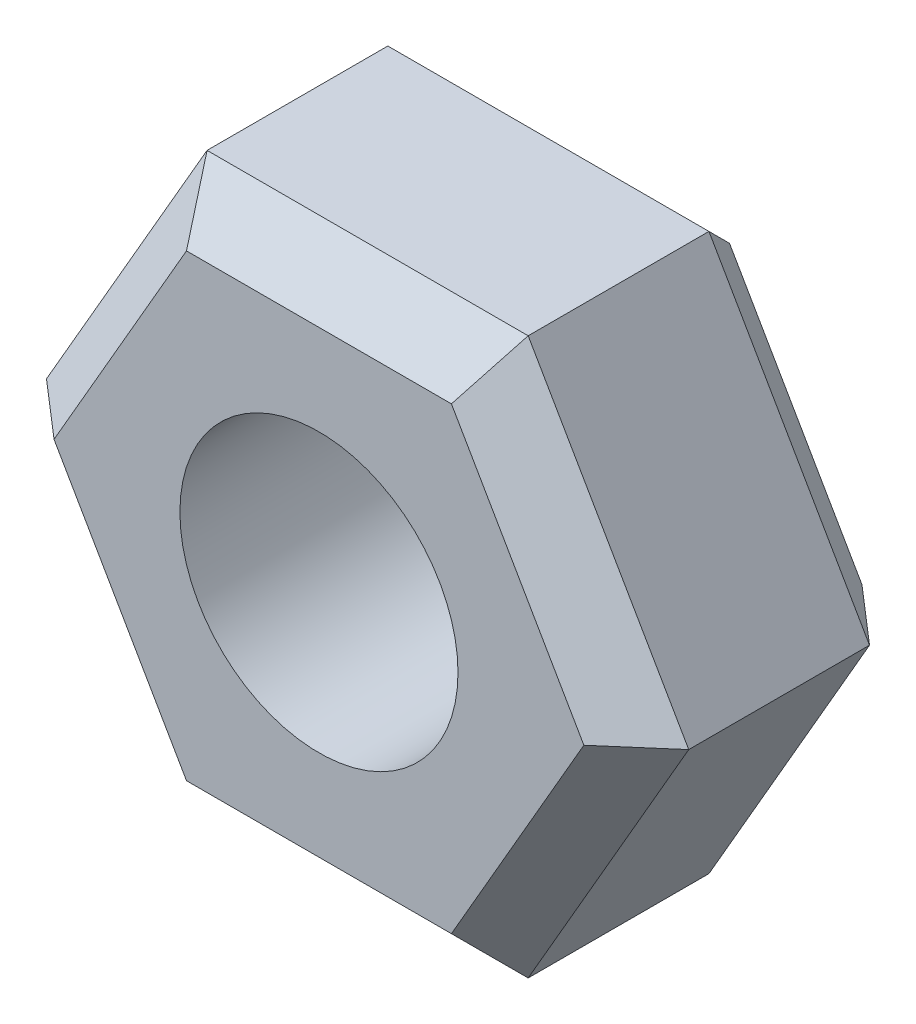
from build123d import *

# Parameters (mm, degrees)
SKETCH1_R      = 1
SHAPE_DEPTH    = 2
CHAMFER_2_SIZE = 0.35


with BuildPart() as part:
    # Sketch1 → Shape (new body)
    with BuildSketch(Plane.XY):
        Polygon((-1.154700538, -2), (1.154700538, -2), (2.309401077, 0), (1.154700538, 2), (-1.154700538, 2), (-2.309401077, 0), align=None)
        Circle(SKETCH1_R, mode=Mode.SUBTRACT)
    extrude(amount=SHAPE_DEPTH)

    # Chamfer 2
    chamfer_2_edges = [part.edges().sort_by_distance(p)[0] for p in [
        (1.732050808, -1, 0),
        (0, -2, 0),
        (-1.732050808, -1, 0),
        (-1.732050808, 1, 0),
        (0, 2, 0),
        (1.732050808, 1, 0),
        (1.732050808, 1, 2),
        (1.732050808, -1, 2),
        (0, -2, 2),
        (-1.732050808, -1, 2),
        (-1.732050808, 1, 2),
        (0, 2, 2),
    ]]
    chamfer(chamfer_2_edges, length=CHAMFER_2_SIZE)


solid = part.part
